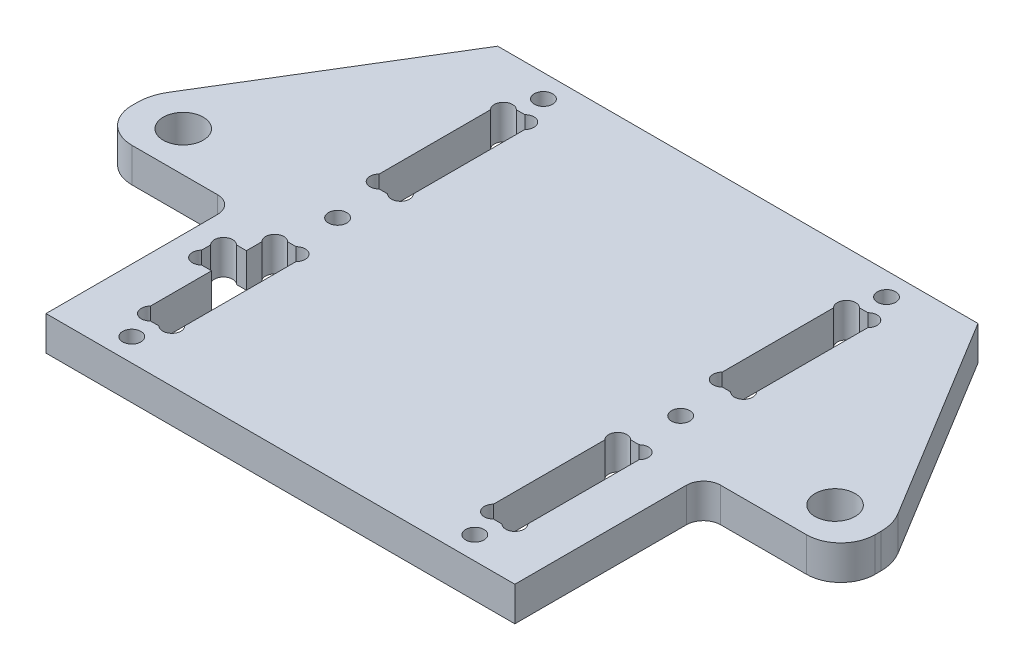
from build123d import *

# Parameters (mm, degrees)
ESQUISSE1_R      = 1.6
ESQUISSE1_R_2    = 3.5
EXTRUSION1_DEPTH = 6


with BuildPart() as part:
    # Esquisse1 → Extrusion1 (new body)
    with BuildSketch(Plane(origin=(0, 0, 0), x_dir=(1, 0, 0), z_dir=(0, 1, 0))):
        with BuildLine():
            Line((42, 80), (63.832091269, 44.162034226))
            ThreePointArc((63.832091269, 44.162034226), (64.702490836, 42.161396522), (65, 40))
            Line((65, 40), (65, 39))
            ThreePointArc((65, 39), (63.242640687, 34.757359313), (59, 33))
            Line((59, 33), (44, 33))
            ThreePointArc((44, 33), (41.878679656, 32.121320344), (41, 30))
            Line((41, 30), (41, 0))
            Line((41, 0), (-41, 0))
            Line((-41, 0), (-41, 30))
            ThreePointArc((-41, 30), (-41.878679656, 32.121320344), (-44, 33))
            Line((-44, 33), (-59, 33))
            ThreePointArc((-59, 33), (-63.242640687, 34.757359313), (-65, 39))
            Line((-65, 39), (-65, 40))
            ThreePointArc((-65, 40), (-64.702490836, 42.161396522), (-63.832091269, 44.162034226))
            Line((-63.832091269, 44.162034226), (-42, 80))
            Line((-42, 80), (42, 80))
        make_face()
        with Locations(Location((-30, 4, 0), (0, 0, 270))):  # turned: the seam where the file's is
            Circle(ESQUISSE1_R, mode=Mode.SUBTRACT)
        with Locations(Location((-30, 76, 0), (0, 0, 90))):  # turned: the seam where the file's is
            Circle(ESQUISSE1_R, mode=Mode.SUBTRACT)
        with Locations(Location((-30, 40, 0), (0, 0, 270))):  # turned: the seam where the file's is
            Circle(ESQUISSE1_R, mode=Mode.SUBTRACT)
        with Locations(Location((57, 40, 0), (0, 0, 90))):  # turned: the seam where the file's is
            Circle(ESQUISSE1_R_2, mode=Mode.SUBTRACT)
        with Locations(Location((30, 4, 0), (0, 0, 90))):  # turned: the seam where the file's is
            Circle(ESQUISSE1_R, mode=Mode.SUBTRACT)
        with Locations(Location((30, 40, 0), (0, 0, 90))):  # turned: the seam where the file's is
            Circle(ESQUISSE1_R, mode=Mode.SUBTRACT)
        with Locations(Location((-57, 40, 0), (0, 0, 270))):  # turned: the seam where the file's is
            Circle(ESQUISSE1_R_2, mode=Mode.SUBTRACT)
        with Locations(Location((30, 76, 0), (0, 0, 270))):  # turned: the seam where the file's is
            Circle(ESQUISSE1_R, mode=Mode.SUBTRACT)
        with BuildLine():
            Line((-33, 50.2627417), (-33, 69.7372583))
            ThreePointArc((-33, 69.7372583), (-33, 72), (-30.7372583, 72))
            Line((-30.7372583, 72), (-29.2627417, 72))
            ThreePointArc((-29.2627417, 72), (-27, 72), (-27, 69.7372583))
            Line((-27, 69.7372583), (-27, 50.2627417))
            ThreePointArc((-27, 50.2627417), (-27, 48), (-29.2627417, 48))
            Line((-29.2627417, 48), (-30.7372583, 48))
            ThreePointArc((-30.7372583, 48), (-33, 48), (-33, 50.2627417))
        make_face(mode=Mode.SUBTRACT)
        with BuildLine():
            Line((-30.7372583, 32), (-29.2627417, 32))
            ThreePointArc((-29.2627417, 32), (-27, 32), (-27, 29.7372583))
            Line((-27, 29.7372583), (-27, 10.2627417))
            ThreePointArc((-27, 10.2627417), (-27, 8), (-29.2627417, 8))
            Line((-29.2627417, 8), (-30.7372583, 8))
            ThreePointArc((-30.7372583, 8), (-33, 8), (-33, 10.2627417))
            Line((-33, 10.2627417), (-33, 20.95))
            Line((-33, 20.95), (-34.7372583, 20.95))
            ThreePointArc((-34.7372583, 20.95), (-37, 20.95), (-37, 23.2127417))
            Line((-37, 23.2127417), (-37, 24.7872583))
            ThreePointArc((-37, 24.7872583), (-37, 27.05), (-34.7372583, 27.05))
            Line((-34.7372583, 27.05), (-33, 27.05))
            Line((-33, 27.05), (-33, 29.7372583))
            ThreePointArc((-33, 29.7372583), (-33, 32), (-30.7372583, 32))
        make_face(mode=Mode.SUBTRACT)
        with BuildLine():
            Line((30.7372583, 72), (29.2627417, 72))
            ThreePointArc((29.2627417, 72), (27, 72), (27, 69.7372583))
            Line((27, 69.7372583), (27, 50.2627417))
            ThreePointArc((27, 50.2627417), (27, 48), (29.2627417, 48))
            Line((29.2627417, 48), (30.7372583, 48))
            ThreePointArc((30.7372583, 48), (33, 48), (33, 50.2627417))
            Line((33, 50.2627417), (33, 69.7372583))
            ThreePointArc((33, 69.7372583), (33, 72), (30.7372583, 72))
        make_face(mode=Mode.SUBTRACT)
        with BuildLine():
            Line((27, 29.7372583), (27, 10.2627417))
            ThreePointArc((27, 10.2627417), (27, 8), (29.2627417, 8))
            Line((29.2627417, 8), (30.7372583, 8))
            ThreePointArc((30.7372583, 8), (33, 8), (33, 10.2627417))
            Line((33, 10.2627417), (33, 29.7372583))
            ThreePointArc((33, 29.7372583), (33, 32), (30.7372583, 32))
            Line((30.7372583, 32), (29.2627417, 32))
            ThreePointArc((29.2627417, 32), (27, 32), (27, 29.7372583))
        make_face(mode=Mode.SUBTRACT)
    extrude(amount=EXTRUSION1_DEPTH)


solid = part.part
